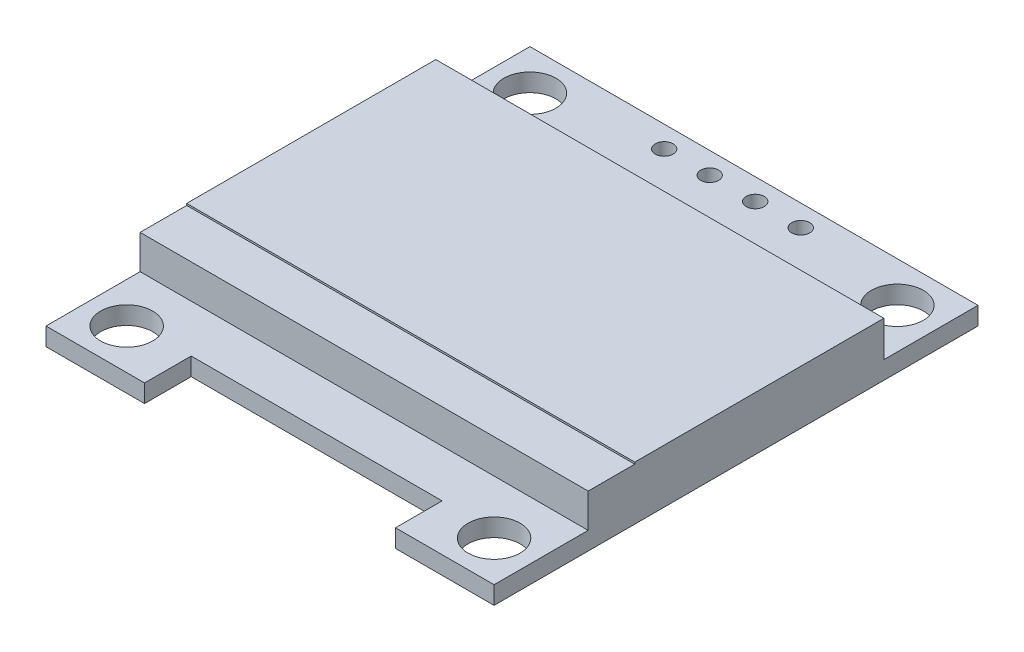
from build123d import *

# Parameters (mm, degrees)
SKETCH_1_W          = 25
SKETCH_1_H          = 27
EXTRUDE_1_DEPTH     = 1
EXTRUDE_START       = -1
SKETCH_2_W          = 25
SKETCH_2_H          = 16.5
EXTRUDE_2_DEPTH     = 2.9
EXTRUDE_START_2     = -2.9
SKETCH_3_W          = 25
SKETCH_3_H          = 13.9
EXTRUDE_3_DEPTH     = 3
SKETCH_4_W          = 14
SKETCH_4_H          = 2.6
CUT_EXTRUDE_1_DEPTH = 2
SKETCH_6_R          = 1.45
SKETCH_6_R_2        = 0.5
CUT_EXTRUDE_2_DEPTH = 2
EXTRUDE_START_3     = -3
SKETCH_7_W          = 0.62130337
SKETCH_7_H          = 2.122786517
EXTRUDE_4_DEPTH     = 4


with BuildPart() as part:
    # 草图1 → 凸台-拉伸1 (new body)
    with BuildSketch(Plane(origin=(0, 0, 0), x_dir=(1, 0, 0), z_dir=(0, 1, 0))):
        Rectangle(SKETCH_1_W, SKETCH_1_H)
    extrude(amount=EXTRUDE_1_DEPTH)

    # 草图2 → 凸台-拉伸2 (add)
    with BuildSketch(Plane(origin=(0, 1, 0), x_dir=(1, 0, 0), z_dir=(0, 1, 0)).offset(EXTRUDE_START)):
        Rectangle(SKETCH_2_W, SKETCH_2_H)
    extrude(amount=EXTRUDE_2_DEPTH)

    # 草图3 → 凸台-拉伸3 (add)
    with BuildSketch(Plane(origin=(0, 2.9, 0), x_dir=(1, 0, 0), z_dir=(0, 1, 0)).offset(EXTRUDE_START_2)):
        with Locations((0, 1.3)):
            Rectangle(SKETCH_3_W, SKETCH_3_H)
    extrude(amount=EXTRUDE_3_DEPTH)

    # 草图4 → 切除-拉伸1 (cut, through all)
    with BuildSketch(Plane(origin=(0, 1, 0), x_dir=(1, 0, 0), z_dir=(0, 1, 0))):
        with Locations((0, -12.2)):
            Rectangle(SKETCH_4_W, SKETCH_4_H)
    extrude(amount=-CUT_EXTRUDE_1_DEPTH, mode=Mode.SUBTRACT)

    # 草图6 → 切除-拉伸2 (cut, through all)
    with BuildSketch(Plane(origin=(0, 1, 0), x_dir=(1, 0, 0), z_dir=(0, 1, 0))):
        with Locations((-10.25, 11.25)):
            Circle(SKETCH_6_R)
        with Locations((10.25, 11.25)):
            Circle(SKETCH_6_R)
        with Locations((-10.25, -11.25)):
            Circle(SKETCH_6_R)
        with Locations((10.25, -11.25)):
            Circle(SKETCH_6_R)
        with Locations((-3.81, 12.3)):
            Circle(SKETCH_6_R_2)
        with Locations((-1.27, 12.3)):
            Circle(SKETCH_6_R_2)
        with Locations((1.27, 12.3)):
            Circle(SKETCH_6_R_2)
        with Locations((3.81, 12.3)):
            Circle(SKETCH_6_R_2)
    extrude(amount=-CUT_EXTRUDE_2_DEPTH, mode=Mode.SUBTRACT)

    # 草图7 → 凸台-拉伸4 (add)
    with BuildSketch(Plane.XZ.offset(EXTRUDE_START_3)):
        with Locations((-3.572494382, -3.753707866)):
            Rectangle(SKETCH_7_W, SKETCH_7_H)
    extrude(amount=EXTRUDE_4_DEPTH)


solid = part.part
